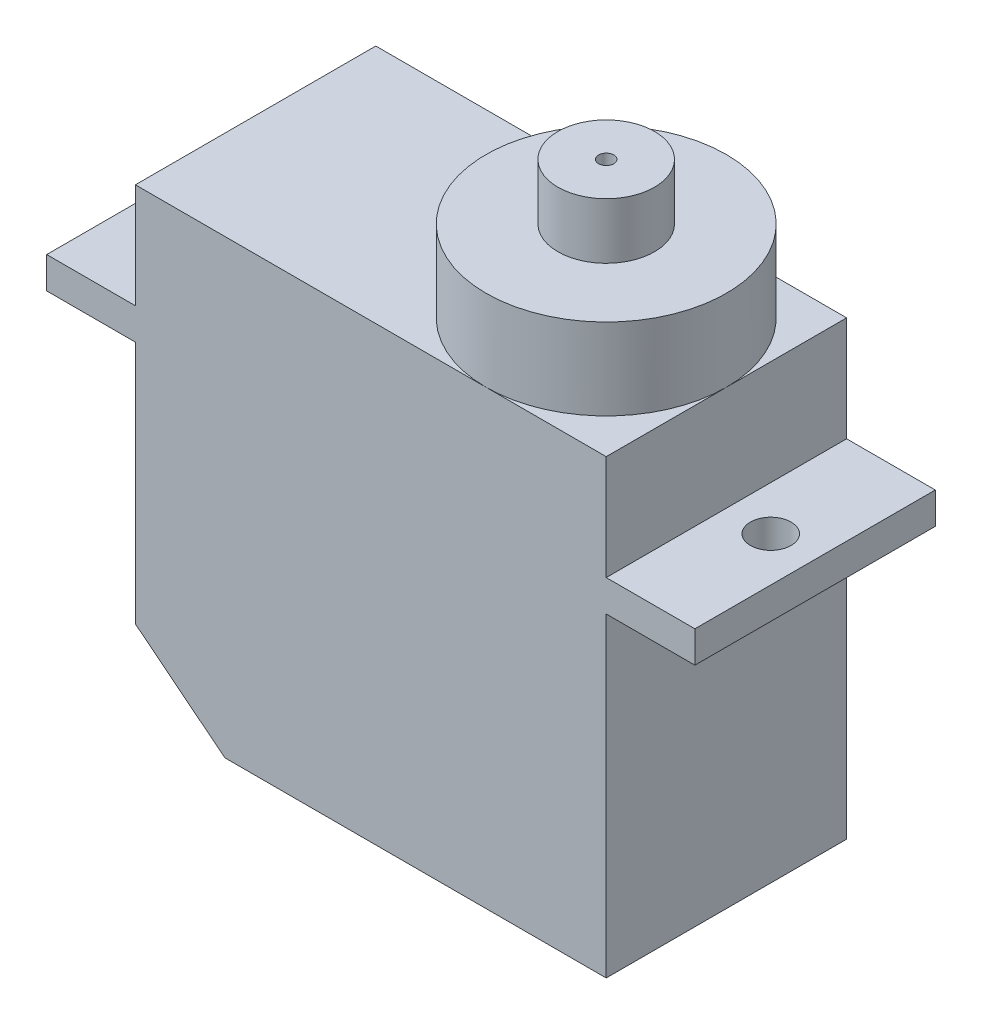
from build123d import *

# Parameters (mm, degrees)
SKETCH1_W           = 23.15
SKETCH1_H           = 11.82
BOSS_EXTRUDE1_DEPTH = 22.2
SKETCH2_W           = 31.87
SKETCH2_H           = 11.82
BOSS_EXTRUDE2_DEPTH = 1.55
SKETCH3_R           = 1
CUT_EXTRUDE1_DEPTH  = 7.7
CUT_EXTRUDE2_DEPTH  = 12.82
SKETCH5_R           = 5.91
BOSS_EXTRUDE3_DEPTH = 4
SKETCH6_R           = 2.375
BOSS_EXTRUDE4_DEPTH = 2.75
SKETCH7_R           = 0.375
CUT_EXTRUDE3_DEPTH  = 2.75


with BuildPart() as part:
    # Sketch1 → Boss-Extrude1 (new body)
    with BuildSketch(Plane(origin=(0, 0, 0), x_dir=(1, 0, 0), z_dir=(0, 1, 0))):
        with Locations((11.575, 5.91)):
            Rectangle(SKETCH1_W, SKETCH1_H)
    extrude(amount=BOSS_EXTRUDE1_DEPTH)

    # Sketch2 → Boss-Extrude2 (add)
    with BuildSketch(Plane(origin=(0, 15.5, 0), x_dir=(-1, 0, 0), z_dir=(0, 1, 0))):
        with Locations((-11.575, -5.91)):
            Rectangle(SKETCH2_W, SKETCH2_H)
    extrude(amount=BOSS_EXTRUDE2_DEPTH)

    # Sketch3 → Cut-Extrude1 (cut, through all)
    with BuildSketch(Plane(origin=(0, 15.5, 0), x_dir=(-1, 0, 0), z_dir=(0, 1, 0))):
        with Locations((-25.33, -5.91)):
            Circle(SKETCH3_R)
        with Locations((2.18, -5.91)):
            Circle(SKETCH3_R)
    extrude(amount=CUT_EXTRUDE1_DEPTH, mode=Mode.SUBTRACT)

    # Sketch4 → Cut-Extrude2 (cut, through all)
    with BuildSketch(Plane.XY):
        Polygon((-3.075644921, 5.946535733), (9.026256409, -3.679976689), (-2.538069932, -3.679976689), align=None)
    extrude(amount=-CUT_EXTRUDE2_DEPTH, mode=Mode.SUBTRACT)

    # Sketch5 → Boss-Extrude3 (add)
    with BuildSketch(Plane(origin=(0, 22.2, 0), x_dir=(1, 0, 0), z_dir=(0, 1, 0))):
        with Locations((17.24, 5.91)):
            Circle(SKETCH5_R)
    extrude(amount=BOSS_EXTRUDE3_DEPTH)

    # Sketch6 → Boss-Extrude4 (add)
    with BuildSketch(Plane(origin=(0, 26.2, 0), x_dir=(1, 0, 0), z_dir=(0, 1, 0))):
        with Locations((17.24, 5.91)):
            Circle(SKETCH6_R)
    extrude(amount=BOSS_EXTRUDE4_DEPTH)

    # Sketch7 → Cut-Extrude3 (cut)
    with BuildSketch(Plane(origin=(0, 28.95, 0), x_dir=(1, 0, 0), z_dir=(0, 1, 0))):
        with Locations((17.24, 5.91)):
            Circle(SKETCH7_R)
    extrude(amount=-CUT_EXTRUDE3_DEPTH, mode=Mode.SUBTRACT)


solid = part.part
